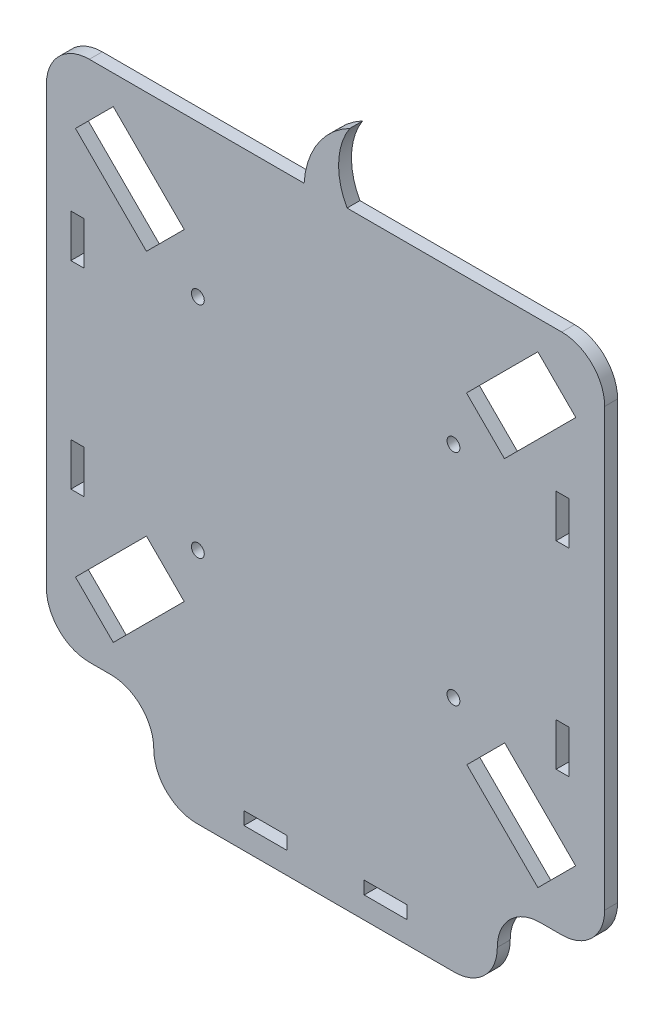
from build123d import *

# Parameters (mm, degrees)
MODEL_W                 = 10
MODEL_H                 = 3
MODEL_W_2               = 3
MODEL_H_2               = 10
MODEL_R                 = 1.5
SALIENTE_EXTRUIR1_DEPTH = 3


with BuildPart() as part:
    # Model → Saliente-Extruir1 (new body)
    with BuildSketch(Plane.XY):
        with BuildLine():
            Line((-10.274239299, -47.526259687), (-5.274229553, -47.526259687))
            ThreePointArc((-5.274229553, -47.526259687), (1.796838258, -50.455191875), (4.725770447, -57.526259687))
            Line((4.725770447, -57.526259687), (4.725770447, -57.532159687))
            ThreePointArc((4.725770447, -57.532159687), (7.654702635, -64.603227499), (14.725770447, -67.532159687))
            Line((14.725770447, -67.532159687), (74.725770447, -67.532159687))
            ThreePointArc((74.725770447, -67.532159687), (81.796838258, -64.603227499), (84.725770447, -57.532159687))
            Line((84.725770447, -57.532159687), (84.725770447, -57.526259687))
            ThreePointArc((84.725770447, -57.526259687), (87.654702635, -50.455191875), (94.725770447, -47.526259687))
            Line((94.725770447, -47.526259687), (99.732474793, -47.526259687))
            ThreePointArc((99.732474793, -47.526259687), (106.803542605, -44.597327499), (109.732474793, -37.526259687))
            Line((109.732474793, -37.526259687), (109.732474793, 64.073740313))
            ThreePointArc((109.732474793, 64.073740313), (106.803542605, 71.144808125), (99.732474793, 74.073740313))
            Line((99.732474793, 74.073740313), (49.729117747, 74.073740313))
            ThreePointArc((49.729117747, 74.073740313), (47.772685887, 82.360468062), (50.374223429, 90.467840313))
            ThreePointArc((50.374223429, 90.467840313), (42.906482031, 83.66371575), (39.729117747, 74.073740313))
            Line((39.729117747, 74.073740313), (-10.274239299, 74.073740313))
            ThreePointArc((-10.274239299, 74.073740313), (-17.345307111, 71.144808125), (-20.274239299, 64.073740313))
            Line((-20.274239299, 64.073740313), (-20.274239299, -37.526259687))
            ThreePointArc((-20.274239299, -37.526259687), (-17.345307111, -44.597327499), (-10.274239299, -47.526259687))
        make_face()
        Polygon((-4.710690354, -40.763410741), (-13.511389214, -31.962709682), (3.012309414, -15.439007345), (11.813010679, -24.239709709), align=None, mode=Mode.SUBTRACT)
        with Locations((30.725760701, -60.959219621)):
            Rectangle(MODEL_W, MODEL_H, mode=Mode.SUBTRACT)
        with Locations((-13.08093725, -9.772535148)):
            Rectangle(MODEL_W_2, MODEL_H_2, mode=Mode.SUBTRACT)
        with Locations((14.984988274, -12.305130612)):
            Circle(MODEL_R, mode=Mode.SUBTRACT)
        Polygon((63.725774778, -62.459219621), (53.725780192, -62.459219621), (53.725780192, -59.459219621), (63.725774778, -59.448813721), align=None, mode=Mode.SUBTRACT)
        Polygon((102.969574793, -31.962759687), (94.16892376, -40.763410719), (77.645224816, -24.239709664), (86.445874793, -15.439059687), align=None, mode=Mode.SUBTRACT)
        with Locations((74.511280689, -12.267097017)):
            Circle(MODEL_R, mode=Mode.SUBTRACT)
        with Locations((99.91359519, -9.772535148)):
            Rectangle(MODEL_W_2, MODEL_H_2, mode=Mode.SUBTRACT)
        with Locations((-13.08093725, 36.320015775)):
            Rectangle(MODEL_W_2, MODEL_H_2, mode=Mode.SUBTRACT)
        with Locations((14.984988274, 38.81446274)):
            Circle(MODEL_R, mode=Mode.SUBTRACT)
        Polygon((-4.710739299, 67.310840313), (11.812961756, 50.787139259), (3.012310656, 41.986490358), (-13.511389299, 58.510190313), align=None, mode=Mode.SUBTRACT)
        with Locations((74.511280689, 38.81446274)):
            Circle(MODEL_R, mode=Mode.SUBTRACT)
        with Locations((99.91359519, 36.320015775)):
            Rectangle(MODEL_W_2, MODEL_H_2, mode=Mode.SUBTRACT)
        Polygon((103.007708555, 58.472006804), (86.39069839, 41.854996145), (77.551864592, 50.693831877), (94.168873658, 67.310841438), align=None, mode=Mode.SUBTRACT)
    extrude(amount=SALIENTE_EXTRUIR1_DEPTH)


solid = part.part
